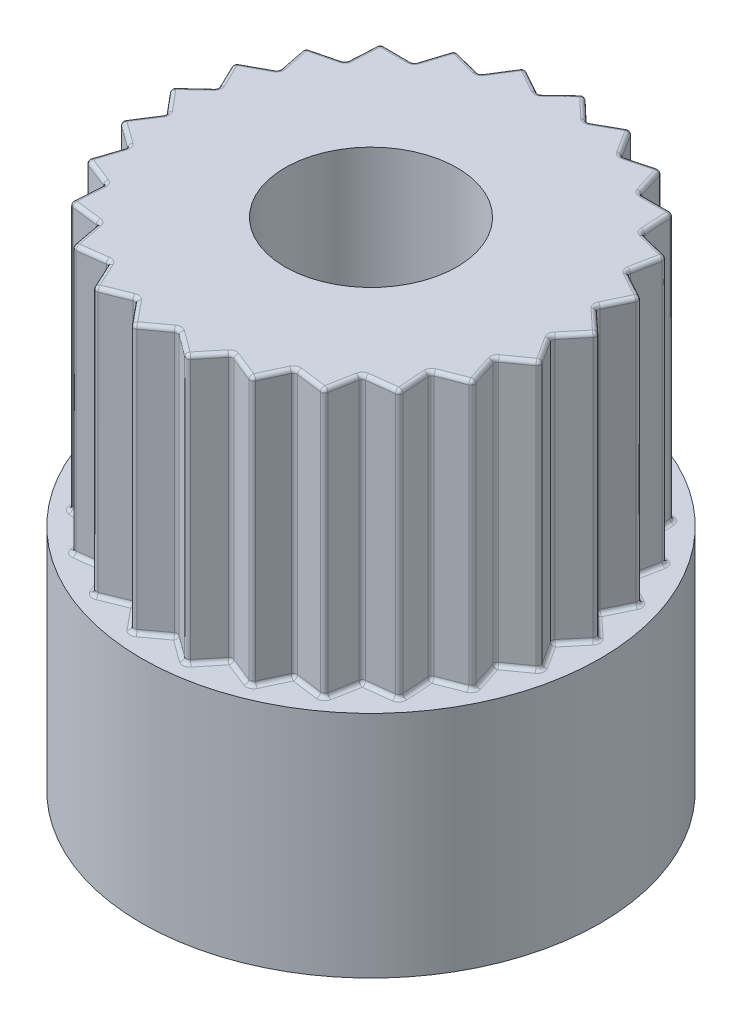
from build123d import *

# Parameters (mm, degrees)
SKETCH1_R           = 3
BOSS_EXTRUDE1_DEPTH = 3
SKETCH2_R           = 2.8
BOSS_EXTRUDE2_DEPTH = 3.5
SKETCH3_R           = 3.664567481
CUT_EXTRUDE2_DEPTH  = 3.5
SKETCH4_R           = 1.125
CUT_EXTRUDE3_DEPTH  = 5.5
FILLET2_R           = 0.05


with BuildPart() as part:
    # Sketch1 → Boss-Extrude1 (new body)
    with BuildSketch(Plane(origin=(0, 0, 0), x_dir=(1, 0, 0), z_dir=(0, 1, 0))):
        Circle(SKETCH1_R)
    extrude(amount=BOSS_EXTRUDE1_DEPTH)

    # Sketch2 → Boss-Extrude2 (add)
    with BuildSketch(Plane(origin=(0, 3, 0), x_dir=(1, 0, 0), z_dir=(0, 1, 0))):
        Circle(SKETCH2_R)
    extrude(amount=BOSS_EXTRUDE2_DEPTH)

    # Sketch3 → Cut-Extrude2 (cut)
    with BuildSketch(Plane(origin=(0, 6.5, 0), x_dir=(1, 0, 0), z_dir=(0, 1, 0))):
        Circle(SKETCH3_R)
        Polygon((0, 2.8), (-0.315823446, 2.5), (-0.696331684, 2.712032851), (-0.92762599, 2.342915806), (-1.348910287, 2.453658704), (-1.481142381, 2.038617595), (-1.916731897, 2.041112157), (-1.941593149, 1.606225543), (-2.364118191, 1.500315026), (-2.280046479, 1.072908432), (-2.662958246, 0.865247584), (-2.475236103, 0.47217654), (-2.79447484, 0.175813455), (-2.514897539, -0.158223942), (-2.750404302, -0.524667681), (-2.396538714, -0.778682631), (-2.533515747, -1.192182016), (-2.127596548, -1.350213827), (-2.15743708, -1.784787171), (-1.724969666, -1.836906122), (-1.645798706, -2.265247584), (-1.213956596, -2.20817885), (-1.030748748, -2.60337416), (-0.626666168, -2.44070358), (-0.350933054, -2.777921164), (0, -2.519869927), (0.350933054, -2.777921164), (0.626666168, -2.44070358), (1.030748748, -2.60337416), (1.213956596, -2.20817885), (1.645798706, -2.265247584), (1.724969666, -1.836906122), (2.15743708, -1.784787171), (2.127596548, -1.350213827), (2.533515747, -1.192182016), (2.396538714, -0.778682631), (2.750404302, -0.524667681), (2.514897539, -0.158223942), (2.79447484, 0.175813455), (2.475236103, 0.47217654), (2.662958246, 0.865247584), (2.280046479, 1.072908432), (2.364118191, 1.500315026), (1.941593149, 1.606225543), (1.916731897, 2.041112157), (1.481142381, 2.038617595), (1.348910287, 2.453658704), (0.92762599, 2.342915806), (0.696331684, 2.712032851), (0.315823446, 2.5), align=None, mode=Mode.SUBTRACT)
    extrude(amount=-CUT_EXTRUDE2_DEPTH, mode=Mode.SUBTRACT)

    # Sketch4 → Cut-Extrude3 (cut)
    with BuildSketch(Plane(origin=(0, 6.5, 0), x_dir=(1, 0, 0), z_dir=(0, 1, 0))):
        Circle(SKETCH4_R)
    extrude(amount=-CUT_EXTRUDE3_DEPTH, mode=Mode.SUBTRACT)

    # Fillet2
    fillet2_edges = [part.edges().sort_by_distance(p)[0] for p in [
        (0.488799611, 3, 2.609312372),
        (0.828707458, 3, 2.52203887),
        (1.122352672, 3, 2.405776505),
        (1.429877651, 3, 2.236713217),
        (1.685384186, 3, 2.051076853),
        (1.941203373, 3, 1.810846647),
        (2.142516814, 3, 1.567500499),
        (2.330556147, 3, 1.271197922),
        (2.465027231, 3, 0.985432324),
        (2.573471508, 3, 0.651675156),
        (2.632650921, 3, 0.341445811),
        (2.654686189, 3, -0.008794756),
        (2.634855471, 3, -0.323994997),
        (2.569097174, 3, -0.668712062),
        (2.471502362, 3, -0.969078008),
        (2.322082335, 3, -1.286611729),
        (2.15285567, 3, -1.553270284),
        (1.929162523, 3, -1.82366885),
        (1.698937139, 3, -2.039864876),
        (1.415026334, 3, -2.246138149),
        (1.138268139, 3, -2.398287255),
        (0.811978837, 3, -2.527474328),
        (0.506077565, 3, -2.606016426),
        (0.157911723, 3, -2.65),
        (-0.157911723, 3, -2.65),
        (-0.506077565, 3, -2.606016426),
        (-0.811978837, 3, -2.527474328),
        (-1.138268139, 3, -2.398287255),
        (-1.415026334, 3, -2.246138149),
        (-1.698937139, 3, -2.039864876),
        (-1.929162523, 3, -1.82366885),
        (-2.15285567, 3, -1.553270284),
        (-2.322082335, 3, -1.286611729),
        (-2.471502362, 3, -0.969078008),
        (-2.569097174, 3, -0.668712062),
        (-2.634855471, 3, -0.323994997),
        (-2.654686189, 3, -0.008794756),
        (-2.632650921, 3, 0.341445811),
        (-2.573471508, 3, 0.651675156),
        (-2.465027231, 3, 0.985432324),
        (-2.330556147, 3, 1.271197922),
        (-2.142516814, 3, 1.567500499),
        (-1.941203373, 3, 1.810846647),
        (-1.685384186, 3, 2.051076853),
        (-1.429877651, 3, 2.236713217),
        (-1.122352672, 3, 2.405776505),
        (-0.828707458, 3, 2.52203887),
        (-0.488799611, 3, 2.609312372),
        (-0.175466527, 3, 2.648895545),
        (0.175466527, 3, 2.648895545),
        (0.157911723, 6.5, -2.65),
        (0.315823446, 4.75, -2.5),
        (0.506077565, 6.5, -2.606016426),
        (0.696331684, 4.75, -2.712032851),
        (0.811978837, 6.5, -2.527474328),
        (0.92762599, 4.75, -2.342915806),
        (1.138268139, 6.5, -2.398287255),
        (1.348910287, 4.75, -2.453658704),
        (1.415026334, 6.5, -2.246138149),
        (1.481142381, 4.75, -2.038617595),
        (1.698937139, 6.5, -2.039864876),
        (1.916731897, 4.75, -2.041112157),
        (1.929162523, 6.5, -1.82366885),
        (1.941593149, 4.75, -1.606225543),
        (2.15285567, 6.5, -1.553270284),
        (2.364118191, 4.75, -1.500315026),
        (2.322082335, 6.5, -1.286611729),
        (2.280046479, 4.75, -1.072908432),
        (2.471502362, 6.5, -0.969078008),
        (2.662958246, 4.75, -0.865247584),
        (2.569097174, 6.5, -0.668712062),
        (2.475236103, 4.75, -0.47217654),
        (2.634855471, 6.5, -0.323994997),
        (2.79447484, 4.75, -0.175813455),
        (2.654686189, 6.5, -0.008794756),
        (2.514897539, 4.75, 0.158223942),
        (2.632650921, 6.5, 0.341445811),
        (2.750404302, 4.75, 0.524667681),
        (2.573471508, 6.5, 0.651675156),
        (2.396538714, 4.75, 0.778682631),
        (2.465027231, 6.5, 0.985432324),
        (2.533515747, 4.75, 1.192182016),
        (2.330556147, 6.5, 1.271197922),
        (2.127596548, 4.75, 1.350213827),
        (2.142516814, 6.5, 1.567500499),
        (2.15743708, 4.75, 1.784787171),
        (1.941203373, 6.5, 1.810846647),
        (1.724969666, 4.75, 1.836906122),
        (1.685384186, 6.5, 2.051076853),
        (1.645798706, 4.75, 2.265247584),
        (1.429877651, 6.5, 2.236713217),
        (1.213956596, 4.75, 2.20817885),
        (1.122352672, 6.5, 2.405776505),
        (1.030748748, 4.75, 2.60337416),
        (0.828707458, 6.5, 2.52203887),
        (0.626666168, 4.75, 2.44070358),
        (0.488799611, 6.5, 2.609312372),
        (0.350933054, 4.75, 2.777921164),
        (0.175466527, 6.5, 2.648895545),
        (0, 4.75, 2.519869927),
        (-0.175466527, 6.5, 2.648895545),
        (-0.350933054, 4.75, 2.777921164),
        (-0.488799611, 6.5, 2.609312372),
        (-0.626666168, 4.75, 2.44070358),
        (-0.828707458, 6.5, 2.52203887),
        (-1.030748748, 4.75, 2.60337416),
        (-1.122352672, 6.5, 2.405776505),
        (-1.213956596, 4.75, 2.20817885),
        (-1.429877651, 6.5, 2.236713217),
        (-1.645798706, 4.75, 2.265247584),
        (-1.685384186, 6.5, 2.051076853),
        (-1.724969666, 4.75, 1.836906122),
        (-1.941203373, 6.5, 1.810846647),
        (-2.15743708, 4.75, 1.784787171),
        (-2.142516814, 6.5, 1.567500499),
        (-2.127596548, 4.75, 1.350213827),
        (-2.330556147, 6.5, 1.271197922),
        (-2.533515747, 4.75, 1.192182016),
        (-2.465027231, 6.5, 0.985432324),
        (-2.396538714, 4.75, 0.778682631),
        (-2.573471508, 6.5, 0.651675156),
        (-2.750404302, 4.75, 0.524667681),
        (-2.632650921, 6.5, 0.341445811),
        (-2.514897539, 4.75, 0.158223942),
        (-2.654686189, 6.5, -0.008794756),
        (-2.79447484, 4.75, -0.175813455),
        (-2.634855471, 6.5, -0.323994997),
        (-2.475236103, 4.75, -0.47217654),
        (-2.569097174, 6.5, -0.668712062),
        (-2.662958246, 4.75, -0.865247584),
        (-2.471502362, 6.5, -0.969078008),
        (-2.280046479, 4.75, -1.072908432),
        (-2.322082335, 6.5, -1.286611729),
        (-2.364118191, 4.75, -1.500315026),
        (-2.15285567, 6.5, -1.553270284),
        (-1.941593149, 4.75, -1.606225543),
        (-1.929162523, 6.5, -1.82366885),
        (-1.916731897, 4.75, -2.041112157),
        (-1.698937139, 6.5, -2.039864876),
        (-1.481142381, 4.75, -2.038617595),
        (-1.415026334, 6.5, -2.246138149),
        (-1.348910287, 4.75, -2.453658704),
        (-1.138268139, 6.5, -2.398287255),
        (-0.92762599, 4.75, -2.342915806),
        (-0.811978837, 6.5, -2.527474328),
        (-0.696331684, 4.75, -2.712032851),
        (-0.506077565, 6.5, -2.606016426),
        (-0.315823446, 4.75, -2.5),
        (-0.157911723, 6.5, -2.65),
        (0, 4.75, -2.8),
    ]]
    fillet(fillet2_edges, radius=FILLET2_R)


solid = part.part
